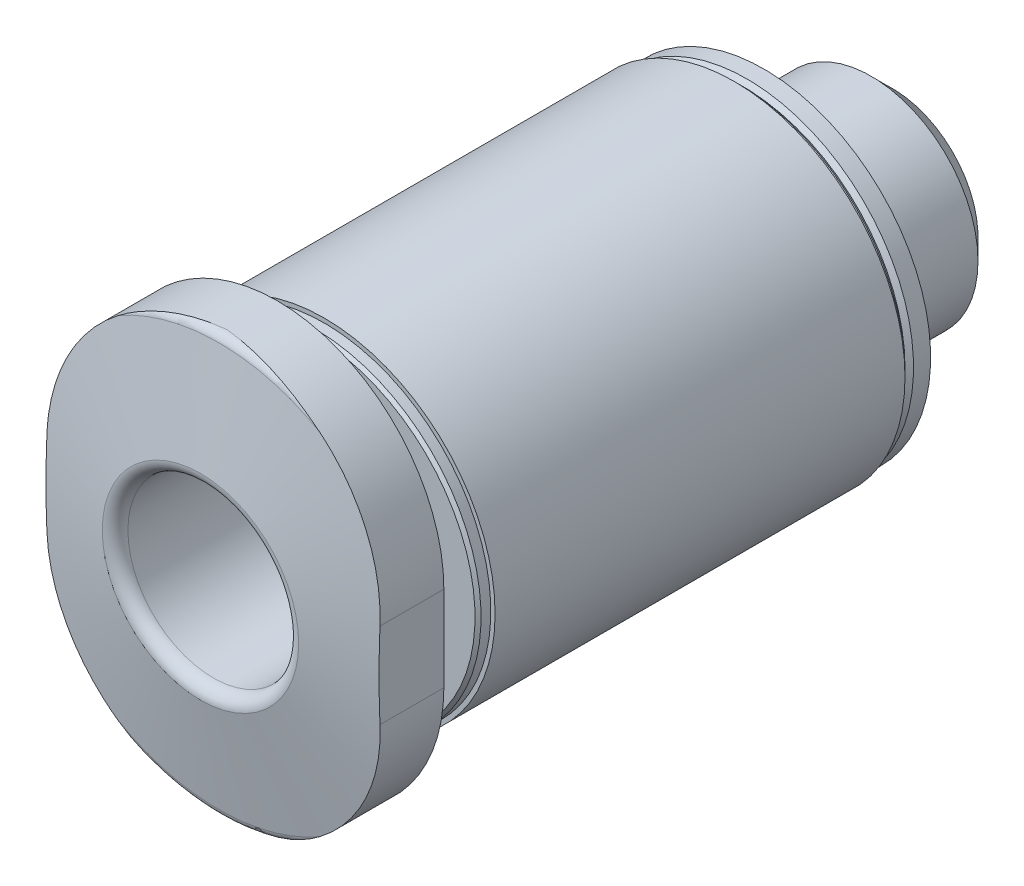
from build123d import *

# Parameters (mm, degrees)
CUT_EXTRUDE1_DEPTH = 4.7
SKETCH3_W          = 20
SKETCH3_H          = 20
CUT_EXTRUDE2_DEPTH = 2


with BuildPart() as part:
    # Sketch1 → Revolve1 (revolve)
    with BuildSketch(Plane(origin=(0, 0, 0), x_dir=(0, 0, -1), z_dir=(1, 0, 0))):
        with BuildLine():
            Line((-1.7, 0), (-1.7, 2))
            Line((-1.7, 2), (-12.9, 2))
            ThreePointArc((-12.9, 2), (-13.112132034, 2.087867966), (-13.2, 2.3))
            Line((-13.2, 2.3), (-12.770691475, 4.734729636))
            ThreePointArc((-12.770691475, 4.734729636), (-12.702287446, 4.853208889), (-12.573729924, 4.9))
            Line((-12.573729924, 4.9), (-11.4, 4.9))
            Line((-11.4, 4.9), (-11.4, 3.075))
            ThreePointArc((-11.4, 3.075), (-11.290165043, 2.809834957), (-11.025, 2.7))
            Line((-11.025, 2.7), (-10.6, 2.7))
            Line((-10.6, 2.7), (-10.6, 3.829289322))
            Line((-10.6, 3.829289322), (-10.529289322, 3.9))
            Line((-10.529289322, 3.9), (-10.3, 3.9))
            Line((-10.3, 3.9), (-10.3, 4))
            Line((-10.3, 4), (-0.7, 4))
            Line((-0.7, 4), (-0.7, 3.9))
            Line((-0.7, 3.9), (-0.6, 3.9))
            Line((-0.6, 3.9), (-0.5, 3.8))
            Line((-0.5, 3.8), (-0.4, 3.9))
            Line((-0.4, 3.9), (0, 3.9))
            Line((0, 3.9), (0, 2.5))
            Line((0, 2.5), (2.5095, 2.5))
            Line((2.5095, 2.5), (3, 2.0095))
            Line((3, 2.0095), (3, 0))
            Line((3, 0), (-1.7, 0))
        make_face()
    revolve(axis=Axis((0, 0, -3), (0, 0, 1)))

    # Sketch2 → Cut-Extrude1 (cut)
    with BuildSketch(Plane.XY.offset(-3)):
        Polygon((-1.25, -0.721687836), (0, -1.443375673), (1.25, -0.721687836), (1.25, 0.721687836), (0, 1.443375673), (-1.25, 0.721687836), align=None)
    extrude(amount=CUT_EXTRUDE1_DEPTH, mode=Mode.SUBTRACT)

    # Sketch3 → Cut-Extrude2 (cut)
    with BuildSketch(Plane.XY.offset(13.2)):
        Rectangle(SKETCH3_W, SKETCH3_H)
        with BuildLine():
            Line((-3.9, 1), (-3.9, -1))
            ThreePointArc((-3.9, -1), (0, -4.899999854), (3.9, -1))
            Line((3.9, -1), (3.9, 1))
            ThreePointArc((3.9, 1), (0, 4.9), (-3.9, 1))
        make_face(mode=Mode.SUBTRACT)
    extrude(amount=-CUT_EXTRUDE2_DEPTH, mode=Mode.SUBTRACT)


solid = part.part
